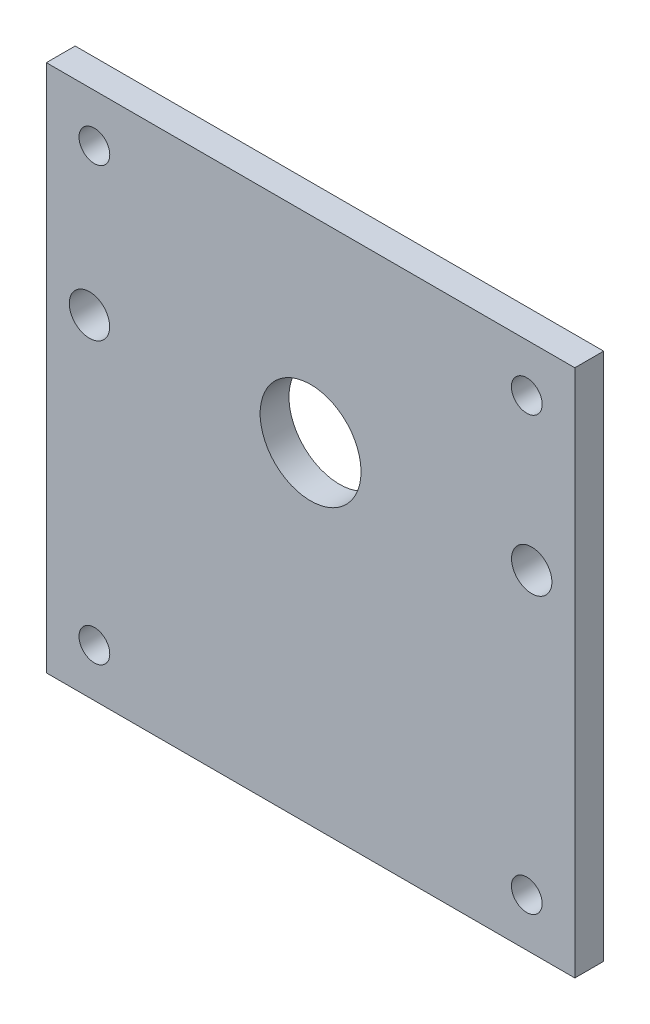
from build123d import *

# Parameters (mm, degrees)
SKETCH_1_W      = 55
SKETCH_1_H      = 55
SKETCH_1_R      = 5.25
SKETCH_1_R_2    = 1.6
SKETCH_1_R_3    = 2.1
EXTRUDE_1_DEPTH = 3


with BuildPart() as part:
    # ｽｹｯﾁ1 → ﾎﾞｽ - 押し出し1 (new body)
    with BuildSketch(Plane.XY):
        Rectangle(SKETCH_1_W, SKETCH_1_H)
        with Locations((0, 7)):
            Circle(SKETCH_1_R, mode=Mode.SUBTRACT)
        with Locations((-22.5, 22.5)):
            Circle(SKETCH_1_R_2, mode=Mode.SUBTRACT)
        with Locations((22.5, 22.5)):
            Circle(SKETCH_1_R_2, mode=Mode.SUBTRACT)
        with Locations((-22.5, -22.5)):
            Circle(SKETCH_1_R_2, mode=Mode.SUBTRACT)
        with Locations((22.5, -22.5)):
            Circle(SKETCH_1_R_2, mode=Mode.SUBTRACT)
        with Locations((-23.0125, 7)):
            Circle(SKETCH_1_R_3, mode=Mode.SUBTRACT)
        with Locations((23.0125, 7)):
            Circle(SKETCH_1_R_3, mode=Mode.SUBTRACT)
    extrude(amount=EXTRUDE_1_DEPTH)


solid = part.part
